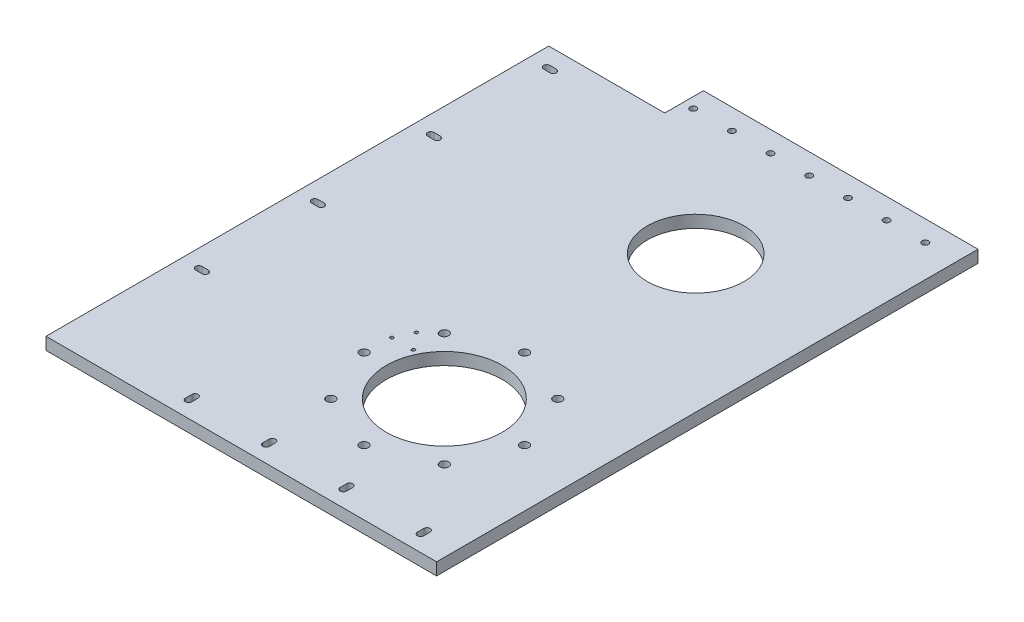
from build123d import *

# Parameters (mm, degrees)
BOSS_EXTRUDE1_DEPTH = 6.35
SKETCH2_R           = 2.25
SKETCH2_R_2         = 30
CUT_EXTRUDE1_DEPTH  = 7.35
SKETCH6_R           = 0.85
CUT_EXTRUDE5_DEPTH  = 7.35
SKETCH8_R           = 25
CUT_EXTRUDE9_DEPTH  = 7.35
SKETCH9_R           = 1.65
CUT_EXTRUDE10_DEPTH = 30
CUT_EXTRUDE12_DEPTH = 30
SKETCH10_R          = 1.65
CUT_EXTRUDE13_DEPTH = 10


with BuildPart() as part:
    # Sketch1 → Boss-Extrude1 (new body)
    with BuildSketch(Plane(origin=(0, 0, 0), x_dir=(1, 0, 0), z_dir=(0, 1, 0))):
        Polygon((-71, 140), (71, 140), (71, -140), (-131, -140), (-131, 120), (-71, 120), align=None)
    extrude(amount=BOSS_EXTRUDE1_DEPTH)

    # Sketch2 → Cut-Extrude1 (cut, through all)
    with BuildSketch(Plane(origin=(0, 6.35, 0), x_dir=(1, 0, 0), z_dir=(0, 1, 0))):
        with Locations((0, -23.5)):
            Circle(SKETCH2_R)
        with Locations((29.344931419, -35.655068581)):
            Circle(SKETCH2_R)
        with Locations((41.5, -65)):
            Circle(SKETCH2_R)
        with Locations((29.344931419, -94.344931419)):
            Circle(SKETCH2_R)
        with Locations((0, -106.5)):
            Circle(SKETCH2_R)
        with Locations((-29.344931419, -94.344931419)):
            Circle(SKETCH2_R)
        with Locations((-41.5, -65)):
            Circle(SKETCH2_R)
        with Locations((-29.344931419, -35.655068581)):
            Circle(SKETCH2_R)
        with Locations((0, -65)):
            Circle(SKETCH2_R_2)
    extrude(amount=-CUT_EXTRUDE1_DEPTH, mode=Mode.SUBTRACT)

    # Sketch6 → Cut-Extrude5 (cut, through all)
    with BuildSketch(Plane(origin=(0, 6.35, 0), x_dir=(1, 0, 0), z_dir=(0, 1, 0))):
        with Locations((-36.963798099, -42.522452757)):
            Circle(SKETCH6_R)
        with Locations((-40.978671586, -51.132376734)):
            Circle(SKETCH6_R)
        with Locations((-29.908156972, -51.053597363)):
            Circle(SKETCH6_R)
    extrude(amount=-CUT_EXTRUDE5_DEPTH, mode=Mode.SUBTRACT)

    # Sketch8 → Cut-Extrude9 (cut, through all)
    with BuildSketch(Plane(origin=(0, 6.35, 0), x_dir=(1, 0, 0), z_dir=(0, 1, 0))):
        with Locations((0, 65)):
            Circle(SKETCH8_R)
    extrude(amount=-CUT_EXTRUDE9_DEPTH, mode=Mode.SUBTRACT)

    # Sketch9 → Cut-Extrude10 (cut)
    with BuildSketch(Plane(origin=(0, 0, 0), x_dir=(-1, 0, 0), z_dir=(0, -1, 0))):
        with Locations((45.6, 129.325)):
            Circle(SKETCH9_R)
        with Locations((5.6, 129.325)):
            Circle(SKETCH9_R)
        with Locations((-34.4, 129.325)):
            Circle(SKETCH9_R)
        with Locations((65.6, 129.325)):
            Circle(SKETCH9_R)
        with Locations((25.6, 129.325)):
            Circle(SKETCH9_R)
        with Locations((-14.4, 129.325)):
            Circle(SKETCH9_R)
        with Locations((-54.4, 129.325)):
            Circle(SKETCH9_R)
    extrude(amount=-CUT_EXTRUDE10_DEPTH, mode=Mode.SUBTRACT)

    # Sketch11 → Cut-Extrude12 (cut)
    with BuildSketch(Plane(origin=(0, 6.35, 0), x_dir=(1, 0, 0), z_dir=(0, 1, 0))):
        with BuildLine():
            Line((-63.95, -128.355), (-63.95, -131.655))
            ThreePointArc((-63.95, -131.655), (-65.6, -133.305), (-67.25, -131.655))
            Line((-67.25, -131.655), (-67.25, -128.355))
            ThreePointArc((-67.25, -128.355), (-65.6, -126.705), (-63.95, -128.355))
        make_face()
        with BuildLine():
            Line((-23.95, -128.353535871), (-23.95, -131.653535871))
            ThreePointArc((-23.95, -131.653535871), (-25.6, -133.303535871), (-27.25, -131.653535871))
            Line((-27.25, -131.653535871), (-27.25, -128.353535871))
            ThreePointArc((-27.25, -128.353535871), (-25.6, -126.703535871), (-23.95, -128.353535871))
        make_face()
        with BuildLine():
            Line((16.05, -128.352071742), (16.05, -131.652071742))
            ThreePointArc((16.05, -131.652071742), (14.4, -133.302071742), (12.75, -131.652071742))
            Line((12.75, -131.652071742), (12.75, -128.352071742))
            ThreePointArc((12.75, -128.352071742), (14.4, -126.702071742), (16.05, -128.352071742))
        make_face()
        with BuildLine():
            Line((56.05, -128.350607613), (56.05, -131.650607613))
            ThreePointArc((56.05, -131.650607613), (54.4, -133.300607613), (52.75, -131.650607613))
            Line((52.75, -131.650607613), (52.75, -128.350607613))
            ThreePointArc((52.75, -128.350607613), (54.4, -126.700607613), (56.05, -128.350607613))
        make_face()
    extrude(amount=-CUT_EXTRUDE12_DEPTH, mode=Mode.SUBTRACT)

    # Sketch10 → Cut-Extrude13 (cut)
    with BuildSketch(Plane.XZ):
        with Locations((-120.325, -110)):
            Circle(SKETCH10_R)
        with BuildLine():
            Line((-118.675, -108.35), (-120.325, -108.35))
            ThreePointArc((-120.325, -108.35), (-119.158273811, -108.833273811), (-118.675, -110))
            ThreePointArc((-118.675, -110), (-119.158273801, -111.166726179), (-120.324999972, -111.65))
            Line((-120.324999972, -111.65), (-118.675, -111.65))
            ThreePointArc((-118.675, -111.65), (-117.025, -110), (-118.675, -108.35))
        make_face()
        with BuildLine():
            Line((-120.325, -108.35), (-121.975, -108.35))
            ThreePointArc((-121.975, -108.35), (-123.625, -110), (-121.975, -111.65))
            Line((-121.975, -111.65), (-120.324999972, -111.65))
            ThreePointArc((-120.324999972, -111.65), (-121.975, -110.000000014), (-120.325, -108.35))
        make_face()
        with BuildLine():
            Line((-120.325, -48.35), (-121.975, -48.35))
            ThreePointArc((-121.975, -48.35), (-123.625, -50), (-121.975, -51.65))
            Line((-121.975, -51.65), (-120.325, -51.65))
            ThreePointArc((-120.325, -51.65), (-121.975, -50), (-120.325, -48.35))
        make_face()
        with Locations((-120.325, -50)):
            Circle(SKETCH10_R)
        with BuildLine():
            Line((-118.675, -48.35), (-120.325, -48.35))
            ThreePointArc((-120.325, -48.35), (-119.158273811, -48.833273811), (-118.675, -50))
            ThreePointArc((-118.675, -50), (-119.158273811, -51.166726189), (-120.325, -51.65))
            Line((-120.325, -51.65), (-118.675, -51.65))
            ThreePointArc((-118.675, -51.65), (-117.025, -50), (-118.675, -48.35))
        make_face()
        with BuildLine():
            Line((-120.325, 11.65), (-121.975, 11.65))
            ThreePointArc((-121.975, 11.65), (-123.625, 10), (-121.975, 8.35))
            Line((-121.975, 8.35), (-120.325, 8.35))
            ThreePointArc((-120.325, 8.35), (-121.975, 10), (-120.325, 11.65))
        make_face()
        with Locations((-120.325, 10)):
            Circle(SKETCH10_R)
        with BuildLine():
            Line((-118.675, 11.65), (-120.325, 11.65))
            ThreePointArc((-120.325, 11.65), (-119.158273811, 11.166726189), (-118.675, 10))
            ThreePointArc((-118.675, 10), (-119.158273811, 8.833273811), (-120.325, 8.35))
            Line((-120.325, 8.35), (-118.675, 8.35))
            ThreePointArc((-118.675, 8.35), (-117.025, 10), (-118.675, 11.65))
        make_face()
        with BuildLine():
            Line((-120.325, 71.65), (-121.975, 71.65))
            ThreePointArc((-121.975, 71.65), (-123.625, 70), (-121.975, 68.35))
            Line((-121.975, 68.35), (-120.325, 68.35))
            ThreePointArc((-120.325, 68.35), (-121.975, 70), (-120.325, 71.65))
        make_face()
        with Locations((-120.325, 70)):
            Circle(SKETCH10_R)
        with BuildLine():
            Line((-118.675, 71.65), (-120.325, 71.65))
            ThreePointArc((-120.325, 71.65), (-119.158273811, 71.166726189), (-118.675, 70))
            ThreePointArc((-118.675, 70), (-119.158273811, 68.833273811), (-120.325, 68.35))
            Line((-120.325, 68.35), (-118.675, 68.35))
            ThreePointArc((-118.675, 68.35), (-117.025, 70), (-118.675, 71.65))
        make_face()
    extrude(amount=-CUT_EXTRUDE13_DEPTH, mode=Mode.SUBTRACT)


solid = part.part
